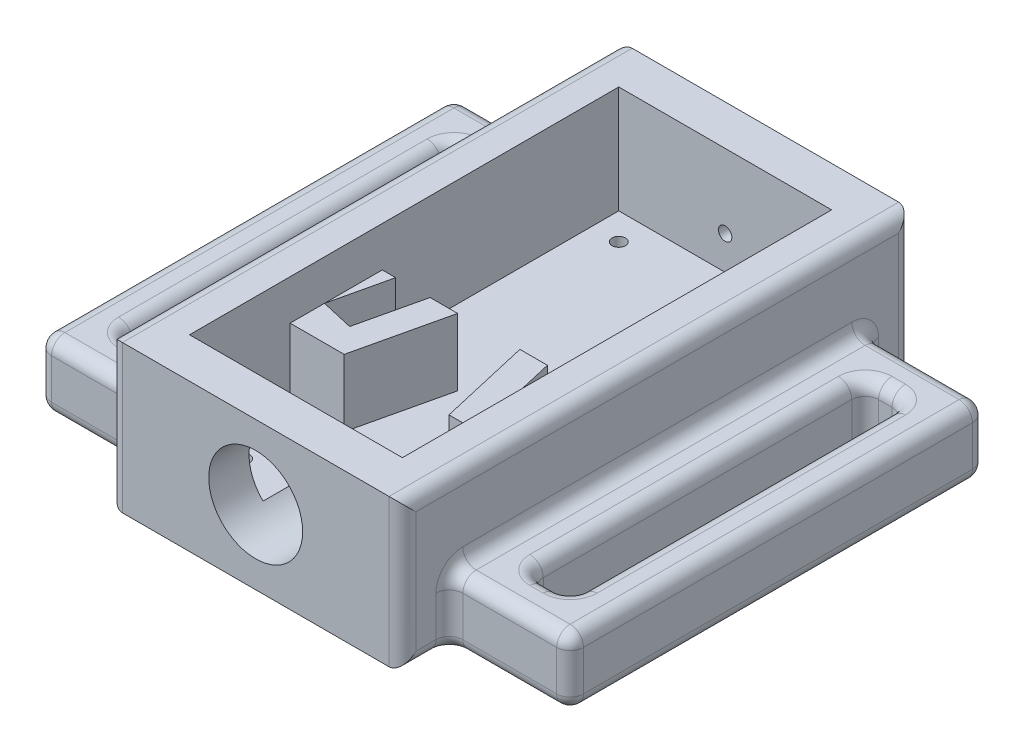
from build123d import *

# Parameters (mm, degrees)
SKETCH1_W           = 21.87178063
SKETCH1_H           = 38
BOSS_EXTRUDE2_DEPTH = 11
SKETCH2_W           = 15.87178063
SKETCH2_H           = 32
CUT_EXTRUDE1_DEPTH  = 8
BOSS_EXTRUDE4_DEPTH = 5
SKETCH4_R           = 3.5
CUT_EXTRUDE2_DEPTH  = 10
SKETCH9_R           = 3.5
CUT_EXTRUDE3_DEPTH  = 1.5
SKETCH8_W           = 8.788754456
SKETCH8_H           = 31
SKETCH8_W_2         = 2.788754456
SKETCH8_H_2         = 25
SKETCH8_W_3         = 9
SKETCH8_W_4         = 3
BOSS_EXTRUDE5_DEPTH = 5
FILLET1_R           = 1
SKETCH10_R          = 0.5
CUT_EXTRUDE4_DEPTH  = 1.5
SKETCH11_R          = 0.5
CUT_EXTRUDE5_DEPTH  = 3


with BuildPart() as part:
    # Sketch1 → Boss-Extrude2 (new body)
    with BuildSketch(Plane(origin=(0, 0, 0), x_dir=(1, 0, 0), z_dir=(0, 1, 0))):
        with Locations((10.935890315, 19)):
            Rectangle(SKETCH1_W, SKETCH1_H)
    extrude(amount=BOSS_EXTRUDE2_DEPTH)

    # Sketch2 → Cut-Extrude1 (cut)
    with BuildSketch(Plane(origin=(0, 11, 0), x_dir=(1, 0, 0), z_dir=(0, 1, 0))):
        with Locations((10.935890315, 19)):
            Rectangle(SKETCH2_W, SKETCH2_H)
    extrude(amount=-CUT_EXTRUDE1_DEPTH, mode=Mode.SUBTRACT)

    # Sketch3 → Boss-Extrude4 (add)
    with BuildSketch(Plane(origin=(0, 3, 0), x_dir=(1, 0, 0), z_dir=(0, 1, 0))):
        Polygon((6.562568566, 17.371850324), (5.437813294, 12.5), (3.001888132, 13.062377636), (3.996808297, 17.371850324), (1.944200081, 17.371850324), (0.357708427, 10.5), (7.028685128, 10.5), (8.615176782, 17.371850324), align=None)
        Polygon((18.87178063, 13.062377636), (16.435855468, 12.5), (15.311100196, 17.371850324), (13.258491981, 17.371850324), (14.844983635, 10.5), (21.515960335, 10.5), (19.929468681, 17.371850324), (17.876860466, 17.371850324), align=None)
    extrude(amount=BOSS_EXTRUDE4_DEPTH)

    # Sketch4 → Cut-Extrude2 (cut)
    with BuildSketch(Plane.XY):
        with Locations((10.93178063, 5.5)):
            Circle(SKETCH4_R)
    extrude(amount=-CUT_EXTRUDE2_DEPTH, mode=Mode.SUBTRACT)

    # Sketch9 → Cut-Extrude3 (cut)
    with BuildSketch(Plane.XY.offset(-38)):
        with Locations((10.93178063, 5.5)):
            Circle(SKETCH9_R)
    extrude(amount=CUT_EXTRUDE3_DEPTH, mode=Mode.SUBTRACT)

    # Sketch8 → Boss-Extrude5 (add)
    with BuildSketch(Plane(origin=(0, 0, 0), x_dir=(1, 0, 0), z_dir=(0, 1, 0))):
        with Locations((-4.394377228, 19)):
            Rectangle(SKETCH8_W, SKETCH8_H)
        with Locations((-4.394377228, 19)):
            Rectangle(SKETCH8_W_2, SKETCH8_H_2, mode=Mode.SUBTRACT)
        with Locations((26.37178063, 19)):
            Rectangle(SKETCH8_W_3, SKETCH8_H)
        with Locations((26.37178063, 19)):
            Rectangle(SKETCH8_W_4, SKETCH8_H_2, mode=Mode.SUBTRACT)
    extrude(amount=BOSS_EXTRUDE5_DEPTH)

    # Fillet1
    fillet1_edges = [part.edges().sort_by_distance(p)[0] for p in [
        (21.87178063, 11, -19),
        (-4.394377228, 5, -31.5),
        (-5.788754456, 2.5, -31.5),
        (21.87178063, 0, -36.25),
        (21.87178063, 5, -19),
        (26.37178063, 5, -3.5),
        (30.87178063, 5, -19),
        (26.37178063, 5, -34.5),
        (26.37178063, 0, -31.5),
        (24.87178063, 0, -19),
        (26.37178063, 0, -6.5),
        (27.87178063, 0, -19),
        (21.87178063, 2.5, -34.5),
        (26.37178063, 0, -3.5),
        (21.87178063, 2.5, -3.5),
        (30.87178063, 0, -19),
        (30.87178063, 2.5, -3.5),
        (26.37178063, 0, -34.5),
        (30.87178063, 2.5, -34.5),
        (24.87178063, 5, -19),
        (24.87178063, 2.5, -6.5),
        (26.37178063, 5, -6.5),
        (27.87178063, 2.5, -6.5),
        (27.87178063, 5, -19),
        (27.87178063, 2.5, -31.5),
        (26.37178063, 5, -31.5),
        (24.87178063, 2.5, -31.5),
        (0, 11, -19),
        (21.87178063, 0, -1.75),
        (0, 0, -1.75),
        (0, 5.5, 0),
        (21.87178063, 5.5, 0),
        (21.87178063, 5.5, -38),
        (0, 5.5, -38),
        (0, 0, -36.25),
        (0, 5, -19),
        (-4.394377228, 5, -34.5),
        (-8.788754456, 5, -19),
        (-4.394377228, 5, -3.5),
        (-5.788754456, 0, -19),
        (-4.394377228, 0, -6.5),
        (-3, 0, -19),
        (-4.394377228, 0, -31.5),
        (0, 2.5, -3.5),
        (-4.394377228, 0, -34.5),
        (0, 2.5, -34.5),
        (-8.788754456, 0, -19),
        (-8.788754456, 2.5, -34.5),
        (-4.394377228, 0, -3.5),
        (-8.788754456, 2.5, -3.5),
        (-5.788754456, 5, -19),
        (-5.788754456, 2.5, -6.5),
        (-4.394377228, 5, -6.5),
        (-3, 2.5, -6.5),
        (-3, 5, -19),
        (-3, 2.5, -31.5),
    ]]
    fillet(fillet1_edges, radius=FILLET1_R)

    # Sketch10 → Cut-Extrude4 (cut)
    with BuildSketch(Plane(origin=(0, 0, -36.5), x_dir=(-1, 0, 0), z_dir=(0, 0, -1))):
        with Locations((-10.93178063, 5.5)):
            Circle(SKETCH10_R)
    extrude(amount=-CUT_EXTRUDE4_DEPTH, mode=Mode.SUBTRACT)

    # Sketch11 → Cut-Extrude5 (cut)
    with BuildSketch(Plane(origin=(0, 3, 0), x_dir=(1, 0, 0), z_dir=(0, 1, 0))):
        with Locations((5, 33)):
            Circle(SKETCH11_R)
        with Locations((16.87178063, 33)):
            Circle(SKETCH11_R)
        with Locations((5, 5)):
            Circle(SKETCH11_R)
        with Locations((16.87178063, 5)):
            Circle(SKETCH11_R)
    extrude(amount=-CUT_EXTRUDE5_DEPTH, mode=Mode.SUBTRACT)


solid = part.part
